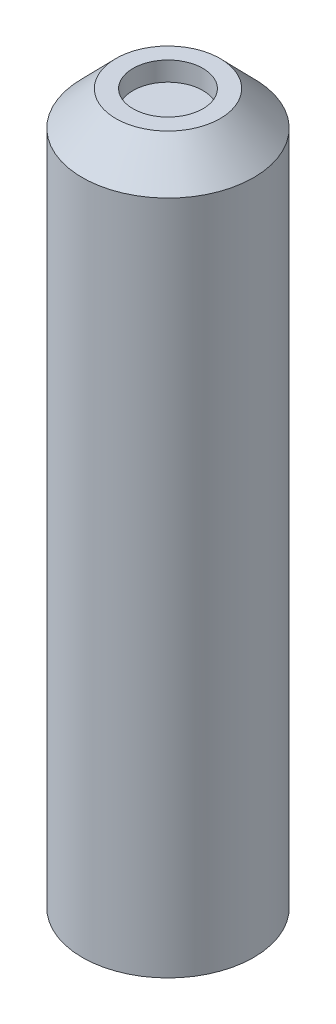
from build123d import *

# Parameters (mm, degrees)
SKETCH1_R           = 12.5
BOSS_EXTRUDE1_DEPTH = 103.5
SKETCH3_R           = 5.101020514
CUT_EXTRUDE1_DEPTH  = 2.8
SKETCH4_R           = 4.25
CUT_EXTRUDE2_DEPTH  = 9.5


with BuildPart() as part:
    # Sketch1 → Boss-Extrude1 (new body)
    with BuildSketch(Plane(origin=(0, 0, 0), x_dir=(1, 0, 0), z_dir=(0, 1, 0))):
        Circle(SKETCH1_R)
    extrude(amount=BOSS_EXTRUDE1_DEPTH)

    # Sketch2 → Cut-Revolve4 (revolve, cut)
    with BuildSketch(Plane(origin=(0, 0, 0), x_dir=(0, 0, -1), z_dir=(1, 0, 0))):
        Polygon((-7.601020514, 103.5), (-12.5, 98.5), (-12.5, 103.5), align=None)
    revolve(axis=Axis((0, 0, 0), (0, 1, 0)), mode=Mode.SUBTRACT)

    # Sketch3 → Cut-Extrude1 (cut)
    with BuildSketch(Plane(origin=(0, 103.5, 0), x_dir=(1, 0, 0), z_dir=(0, 1, 0))):
        Circle(SKETCH3_R)
    extrude(amount=-CUT_EXTRUDE1_DEPTH, mode=Mode.SUBTRACT)

    # Sketch4 → Cut-Extrude2 (cut)
    with BuildSketch(Plane.XZ):
        Circle(SKETCH4_R)
    extrude(amount=-CUT_EXTRUDE2_DEPTH, mode=Mode.SUBTRACT)


solid = part.part
